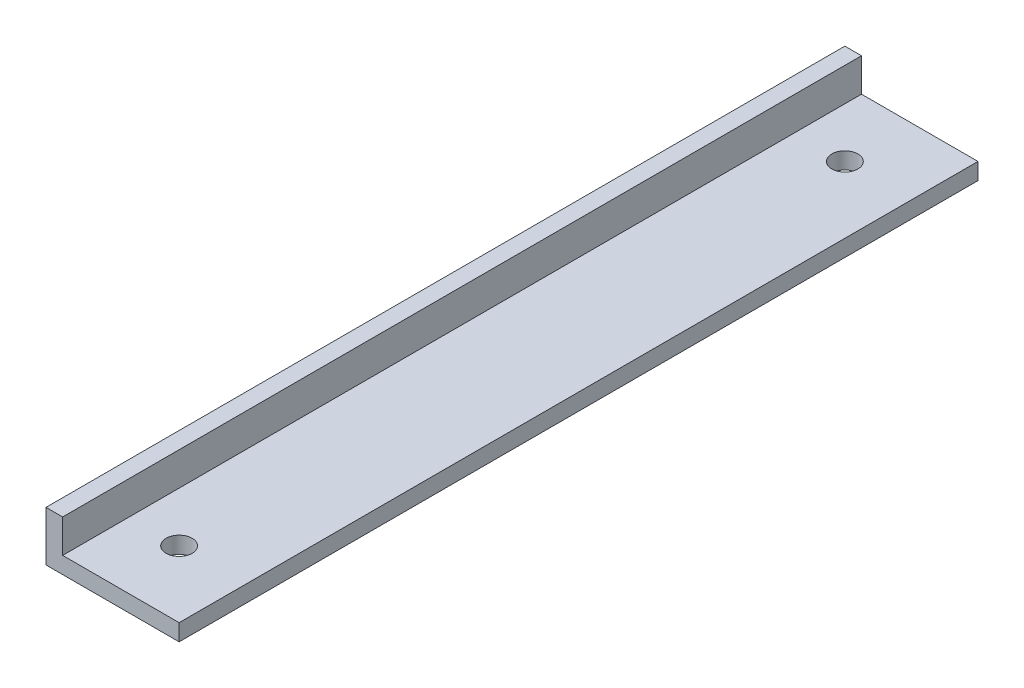
from build123d import *

# Parameters (mm, degrees)
BOSS_EXTRUDE1_DEPTH = 76.2
SKETCH2_R           = 2.4892
CUT_EXTRUDE1_DEPTH  = 4.175


with BuildPart() as part:
    # Sketch1 → Boss-Extrude1 (new body, symmetric)
    with BuildSketch(Plane.XY):
        Polygon((0, 9.525), (0, 0), (25.4, 0), (25.4, 3.175), (3.175, 3.175), (3.175, 9.525), align=None)
    extrude(amount=BOSS_EXTRUDE1_DEPTH, both=True)

    # Sketch2 → Cut-Extrude1 (cut, through all)
    with BuildSketch(Plane(origin=(0, 3.175, 0), x_dir=(1, 0, 0), z_dir=(0, 1, 0))):
        with Locations((12.7, -63.5)):
            Circle(SKETCH2_R)
        with Locations((12.7, 63.5)):
            Circle(SKETCH2_R)
    extrude(amount=-CUT_EXTRUDE1_DEPTH, mode=Mode.SUBTRACT)


solid = part.part
